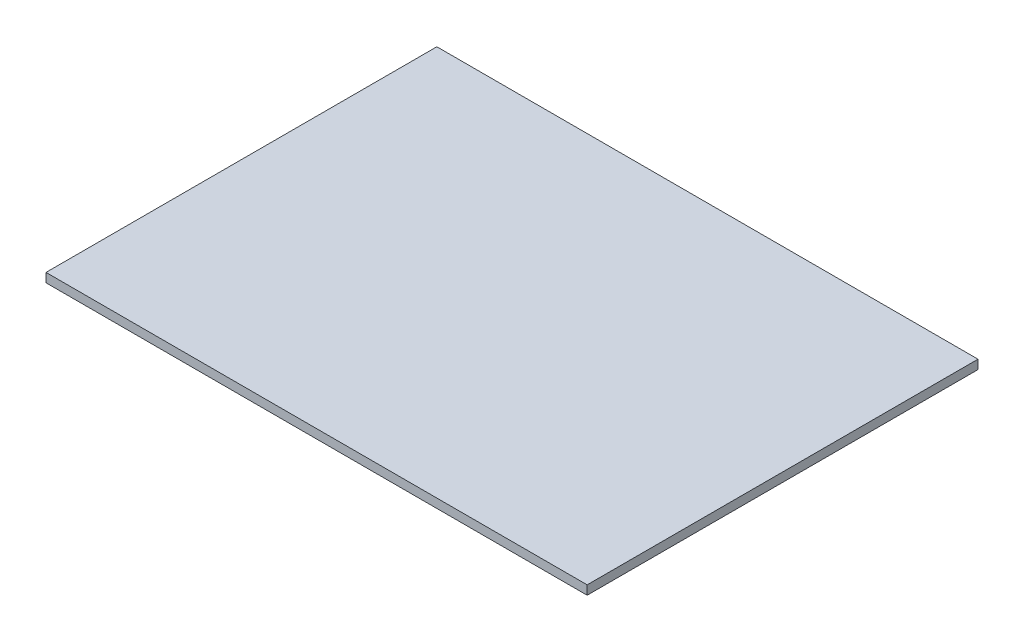
from build123d import *

# Parameters (mm, degrees)
SKETCH1_W           = 900
SKETCH1_H           = 15
EXTRUDE_THIN1_DEPTH = 325


with BuildPart() as part:
    # Sketch1 → Extrude-Thin1 (new body, symmetric)
    with BuildSketch(Plane.XY):
        with Locations((0, 7.5)):
            Rectangle(SKETCH1_W, SKETCH1_H)
    extrude(amount=EXTRUDE_THIN1_DEPTH, both=True)


solid = part.part
